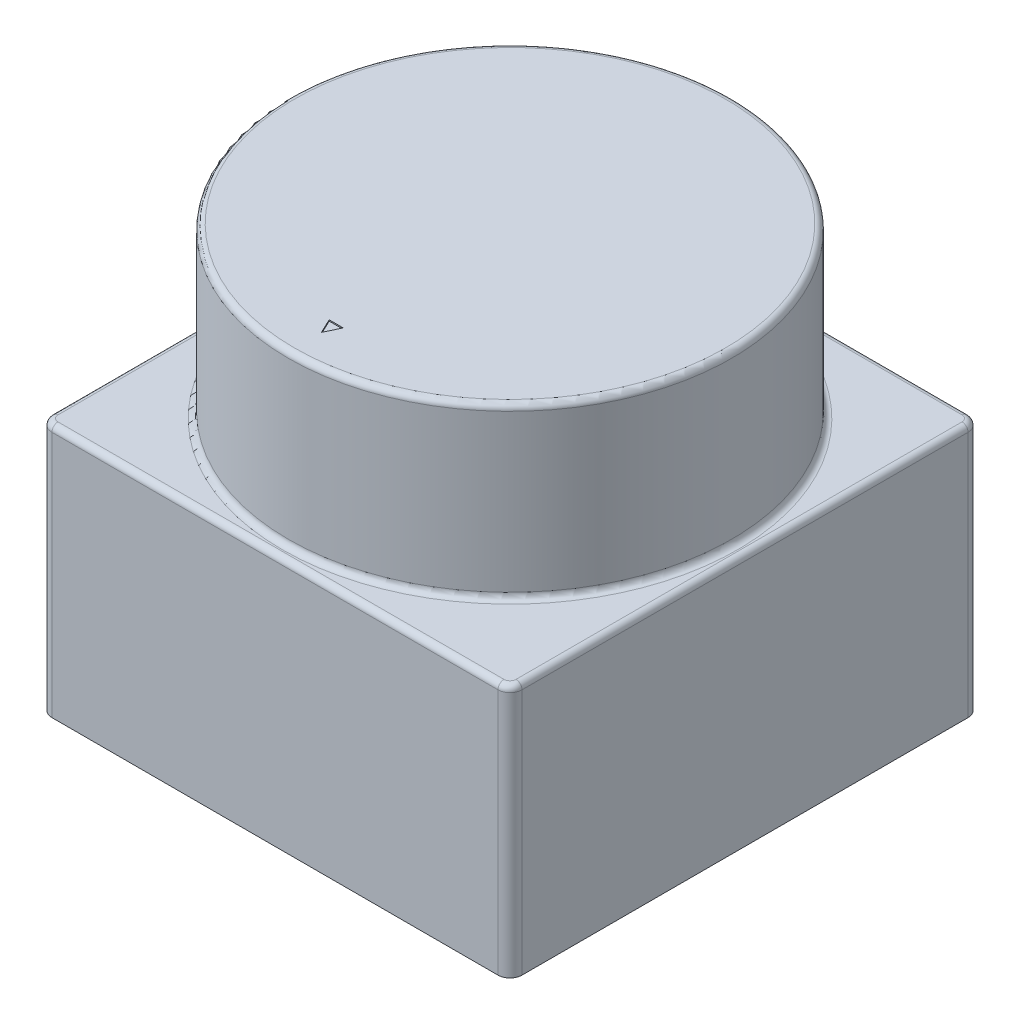
from build123d import *

# Parameters (mm, degrees)
SKETCH_1_W          = 39
SKETCH_1_H          = 39
EXTRUDE_1_DEPTH     = 21
SKETCH_2_R          = 18.38099713
EXTRUDE_2_DEPTH     = 14
FILLET_1_R          = 1
FILLET_2_R          = 0.5
CUT_EXTRUDE_1_DEPTH = 0.1


with BuildPart() as part:
    # 草图1 → 凸台-拉伸1 (new body)
    with BuildSketch(Plane(origin=(0, 0, 0), x_dir=(1, 0, 0), z_dir=(0, 1, 0))):
        Rectangle(SKETCH_1_W, SKETCH_1_H)
    extrude(amount=EXTRUDE_1_DEPTH)

    # 草图2 → 凸台-拉伸2 (add)
    with BuildSketch(Plane(origin=(0, 21, 0), x_dir=(1, 0, 0), z_dir=(0, 1, 0))):
        Circle(SKETCH_2_R)
    extrude(amount=EXTRUDE_2_DEPTH)

    # 圆角1
    fillet_1_edges = [part.edges().sort_by_distance(p)[0] for p in [
        (19.5, 10.5, 19.5),
        (-19.5, 10.5, 19.5),
        (-19.5, 10.5, -19.5),
        (19.5, 10.5, -19.5),
    ]]
    fillet(fillet_1_edges, radius=FILLET_1_R)

    # 圆角2
    fillet_2_edges = [part.edges().sort_by_distance(p)[0] for p in [
        (-18.38099713, 21, 0),
        (-18.38099713, 35, 0),
        (-19.5, 21, 0),
        (0, 21, -19.5),
        (19.5, 21, 0),
        (0, 21, 19.5),
        (19.207106781, 21, -19.207106781),
        (19.207106781, 21, 19.207106781),
        (-19.207106781, 21, 19.207106781),
        (-19.207106781, 21, -19.207106781),
    ]]
    fillet(fillet_2_edges, radius=FILLET_2_R)

    # 草图3 → 切除-拉伸1 (cut)
    with BuildSketch(Plane(origin=(0, 35, 0), x_dir=(1, 0, 0), z_dir=(0, 1, 0))):
        Polygon((0, -15.64459956), (-0.583250004, -14.417555177), (0.583250004, -14.417555177), align=None)
    extrude(amount=-CUT_EXTRUDE_1_DEPTH, mode=Mode.SUBTRACT)


solid = part.part
